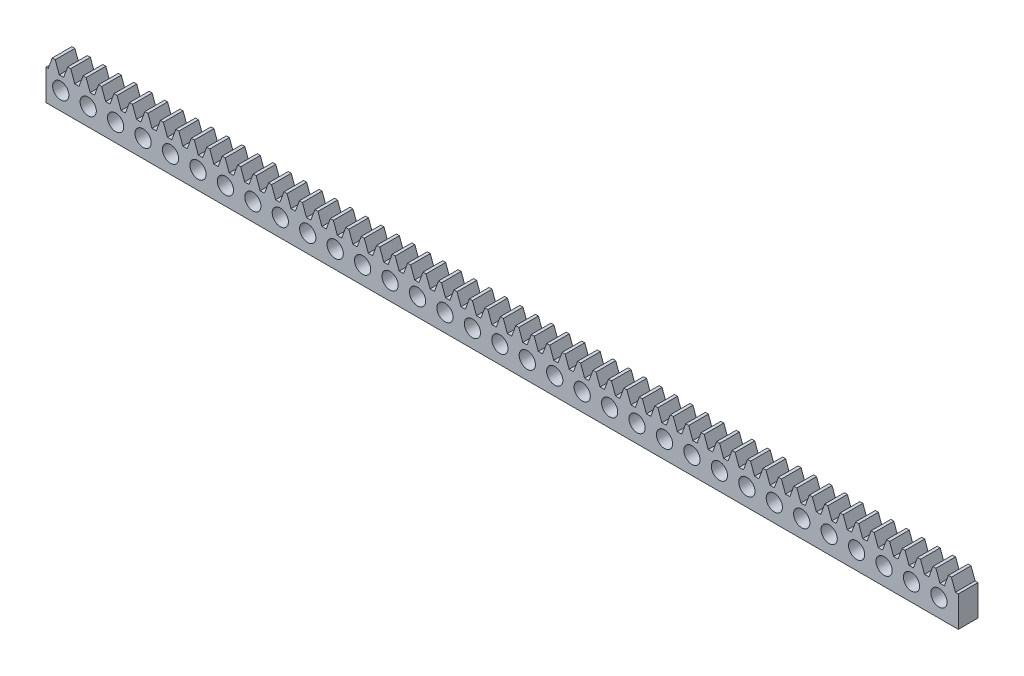
from build123d import *

# Parameters (mm, degrees)
BLANKSKE_W                      = 185.5
BLANKSKE_H                      = 7.5
BLANK_DEPTH                     = 4
TOOTHCUTSIM_DEPTH               = 186.694641818
TEETHCUTS_COUNT                 = 60
TEETHCUTS_PITCH                 = 3.14159265
SKIZZE1_R                       = 1.65
SCHNITT_LINEAR_AUSTRAGEN1_DEPTH = 10
LINEARES_MUSTER1_COUNT          = 33
LINEARES_MUSTER1_PITCH          = 5.58
BASE_LINE_W                     = 185.5
BASE_LINE_H                     = 1
BASE_DEPTH                      = 4


with BuildPart() as part:
    # BlankSke → Blank (new body)
    with BuildSketch(Plane.XY):
        with Locations((92.75, 3.75)):
            Rectangle(BLANKSKE_W, BLANKSKE_H)
    extrude(amount=-BLANK_DEPTH)

    # TooCutSkeSim → ToothCutSim (cut, through all)
    with BuildSketch(Plane.XY):
        Polygon((0.44443537, 5.25), (-0.44443537, 5.25), (-1.272613241, 7.5254), (1.272613241, 7.5254), align=None)
    toothcutsim = extrude(amount=-TOOTHCUTSIM_DEPTH, mode=Mode.SUBTRACT)

    # TeethCuts: ToothCutSim ×60
    with Locations(*[(i * TEETHCUTS_PITCH, 0, 0) for i in range(1, TEETHCUTS_COUNT)]):
        add(toothcutsim, mode=Mode.SUBTRACT)

    # Skizze1 → Schnitt-Linear austragen1 (cut)
    with BuildSketch(Plane.XY):
        with Locations((3, 2.625)):
            Circle(SKIZZE1_R)
    schnitt_linear_austragen1 = extrude(amount=-SCHNITT_LINEAR_AUSTRAGEN1_DEPTH, mode=Mode.SUBTRACT)

    # Lineares Muster1: Schnitt-Linear austragen1 ×33
    with Locations(*[(i * LINEARES_MUSTER1_PITCH, 0, 0) for i in range(1, LINEARES_MUSTER1_COUNT)]):
        add(schnitt_linear_austragen1, mode=Mode.SUBTRACT)

    # base-line → base (add)
    with BuildSketch(Plane.XY):
        with Locations((92.75, -0.5)):
            Rectangle(BASE_LINE_W, BASE_LINE_H)
    extrude(amount=-BASE_DEPTH)


solid = part.part
